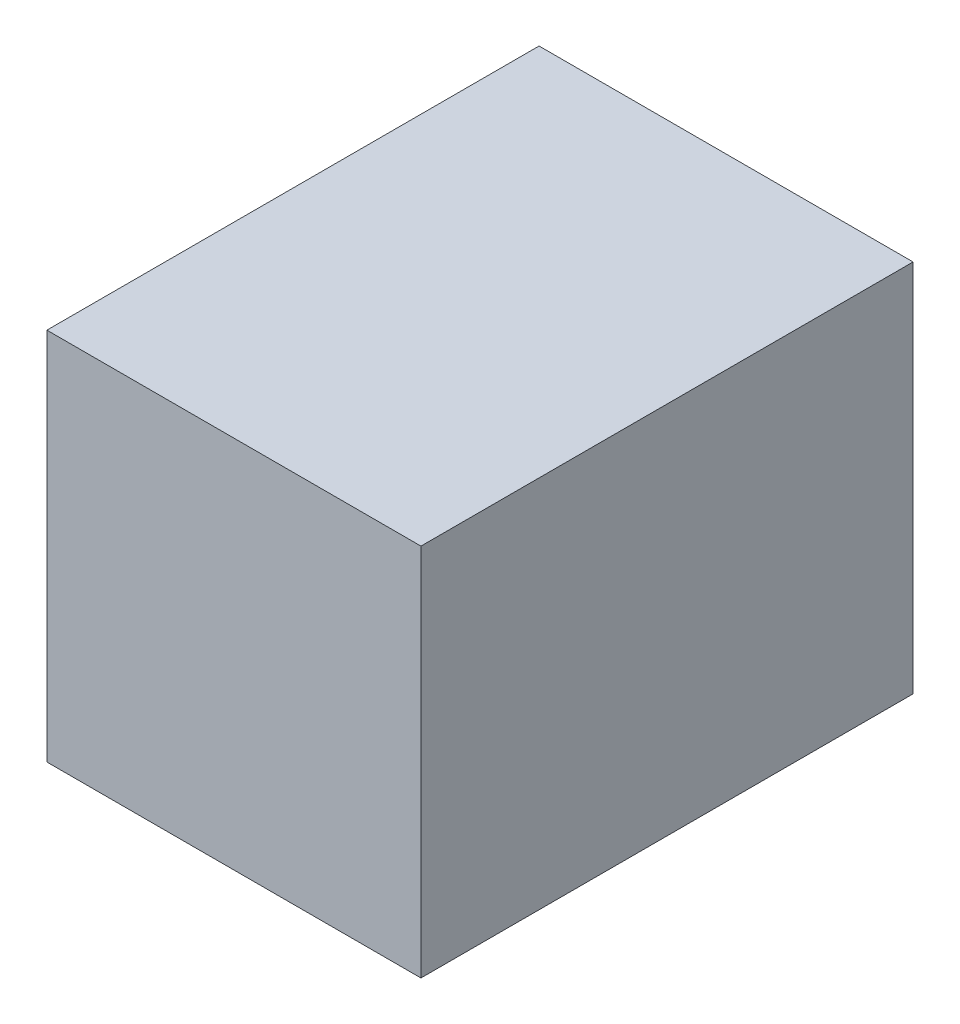
from build123d import *

# Parameters (mm, degrees)
SKETCH1_W           = 19
SKETCH1_H           = 19
BOSS_EXTRUDE1_DEPTH = 12.5


with BuildPart() as part:
    # Sketch1 → Boss-Extrude1 (new body, symmetric)
    with BuildSketch(Plane.XY):
        with Locations((-250, 219.5)):
            Rectangle(SKETCH1_W, SKETCH1_H)
    extrude(amount=BOSS_EXTRUDE1_DEPTH, both=True)


solid = part.part
